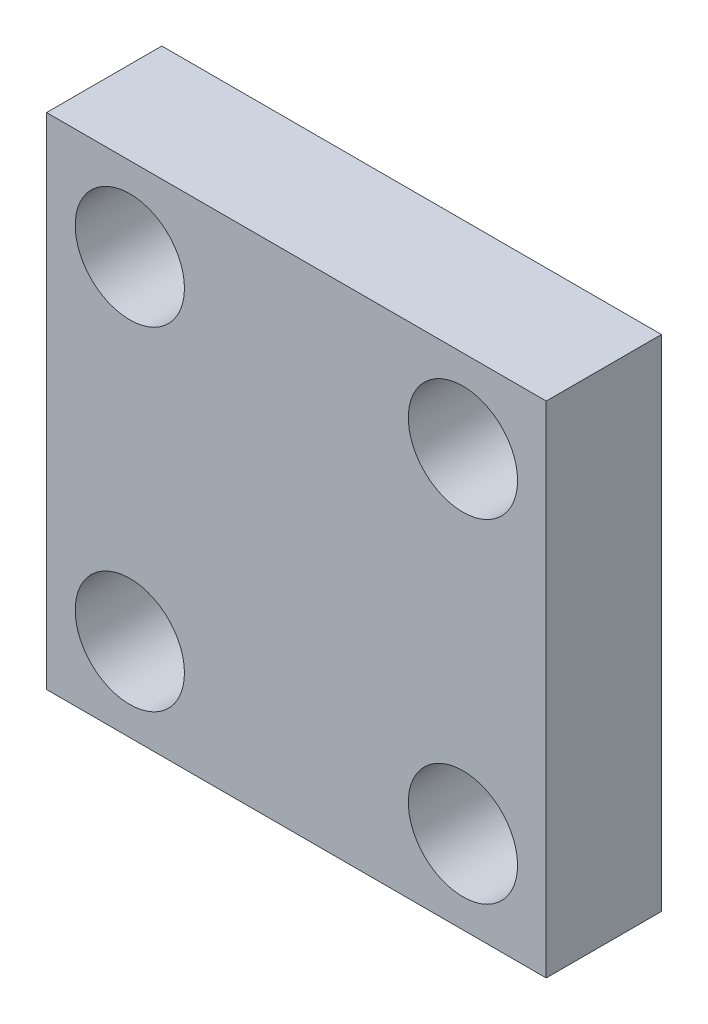
from build123d import *

# Parameters (mm, degrees)
SKETCH1_W           = 19.05
SKETCH1_H           = 19.05
SKETCH1_R           = 2.0828
BOSS_EXTRUDE1_DEPTH = 4.3942


with BuildPart() as part:
    # Sketch1 → Boss-Extrude1 (new body)
    with BuildSketch(Plane.XY):
        with Locations((9.525, 9.525)):
            Rectangle(SKETCH1_W, SKETCH1_H)
        with Locations((3.175, 3.175)):
            Circle(SKETCH1_R, mode=Mode.SUBTRACT)
        with Locations((3.175, 15.875)):
            Circle(SKETCH1_R, mode=Mode.SUBTRACT)
        with Locations((15.875, 15.875)):
            Circle(SKETCH1_R, mode=Mode.SUBTRACT)
        with Locations((15.875, 3.175)):
            Circle(SKETCH1_R, mode=Mode.SUBTRACT)
    extrude(amount=BOSS_EXTRUDE1_DEPTH)


solid = part.part
